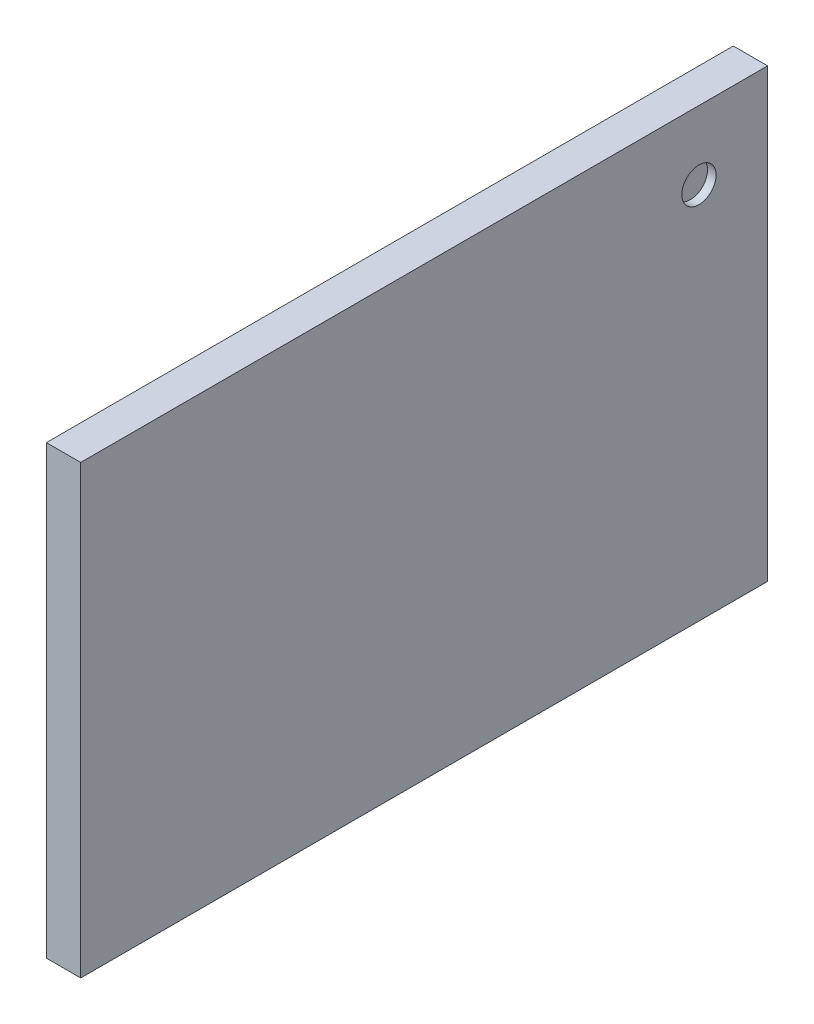
from build123d import *

# Parameters (mm, degrees)
SKETCH1_W           = 508
SKETCH1_H           = 330.2
BOSS_EXTRUDE1_DEPTH = 25.4
SKETCH2_R           = 12.7
CUT_EXTRUDE1_DEPTH  = 6.35


with BuildPart() as part:
    # Sketch1 → Boss-Extrude1 (new body)
    with BuildSketch(Plane(origin=(0, 0, 0), x_dir=(0, 0, -1), z_dir=(1, 0, 0))):
        with Locations((-212.818382353, -138.299264706)):
            Rectangle(SKETCH1_W, SKETCH1_H)
    extrude(amount=BOSS_EXTRUDE1_DEPTH)

    # Sketch2 → Cut-Extrude1 (cut)
    with BuildSketch(Plane(origin=(25.4, 0, 0), x_dir=(0, 0, -1), z_dir=(1, 0, 0))):
        with Locations((-9.618382353, -23.999264706)):
            Circle(SKETCH2_R)
    extrude(amount=-CUT_EXTRUDE1_DEPTH, mode=Mode.SUBTRACT)


solid = part.part
